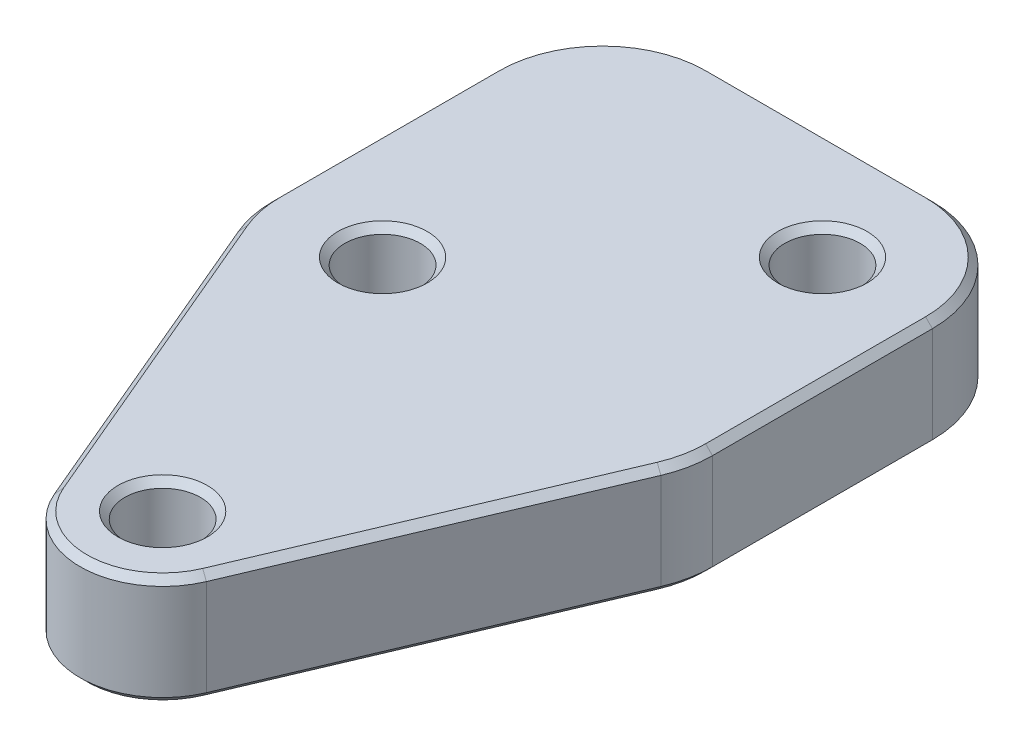
from build123d import *

# Parameters (mm, degrees)
SKETCH1_R           = 2.1828125
BOSS_EXTRUDE1_DEPTH = 6.35
CHAMFER1_SIZE       = 0.396875


with BuildPart() as part:
    # Sketch1 → Boss-Extrude1 (new body)
    with BuildSketch(Plane(origin=(0, 0, 0), x_dir=(1, 0, 0), z_dir=(0, 1, 0))):
        with BuildLine():
            Line((-12.7, 19.05), (-12.7, 31.75))
            ThreePointArc((-12.7, 31.75), (-10.840128061, 36.240128061), (-6.35, 38.1))
            Line((-6.35, 38.1), (6.35, 38.1))
            ThreePointArc((6.35, 38.1), (10.840128061, 36.240128061), (12.7, 31.75))
            Line((12.7, 31.75), (12.7, 19.05))
            ThreePointArc((12.7, 19.05), (12.572860713, 17.785680204), (12.196534001, 16.571988666))
            Line((12.196534001, 16.571988666), (4.384900501, -1.8585085))
            ThreePointArc((4.384900501, -1.8585085), (0, -4.7625), (-4.384900501, -1.8585085))
            Line((-4.384900501, -1.8585085), (-12.196534001, 16.571988666))
            ThreePointArc((-12.196534001, 16.571988666), (-12.572860713, 17.785680204), (-12.7, 19.05))
        make_face()
        Circle(SKETCH1_R, mode=Mode.SUBTRACT)
        with Locations((6.35, 31.75)):
            Circle(SKETCH1_R, mode=Mode.SUBTRACT)
        with Locations((-6.35, 19.05)):
            Circle(SKETCH1_R, mode=Mode.SUBTRACT)
    extrude(amount=BOSS_EXTRUDE1_DEPTH)

    # Chamfer1
    chamfer1_edges = [part.edges().sort_by_distance(p)[0] for p in [
        (8.290717251, 0, -7.356740083),
        (0, 0, 4.7625),
        (-8.290717251, 0, -7.356740083),
        (-12.572860713, 0, -17.785680204),
        (-12.7, 0, -25.4),
        (-10.840128061, 0, -36.240128061),
        (0, 0, -38.1),
        (10.840128061, 6.35, -36.240128061),
        (10.840128061, 0, -36.240128061),
        (12.7, 0, -25.4),
        (12.572860713, 0, -17.785680204),
        (0, 6.35, -38.1),
        (-10.840128061, 6.35, -36.240128061),
        (-12.7, 6.35, -25.4),
        (-2.1828125, 0, 0),
        (-2.1828125, 6.35, 0),
        (-12.572860713, 6.35, -17.785680204),
        (4.1671875, 0, -31.75),
        (4.1671875, 6.35, -31.75),
        (-8.290717251, 6.35, -7.356740083),
        (-8.5328125, 0, -19.05),
        (-8.5328125, 6.35, -19.05),
        (0, 6.35, 4.7625),
        (8.290717251, 6.35, -7.356740083),
        (12.572860713, 6.35, -17.785680204),
        (12.7, 6.35, -25.4),
    ]]
    chamfer(chamfer1_edges, length=CHAMFER1_SIZE)


solid = part.part
